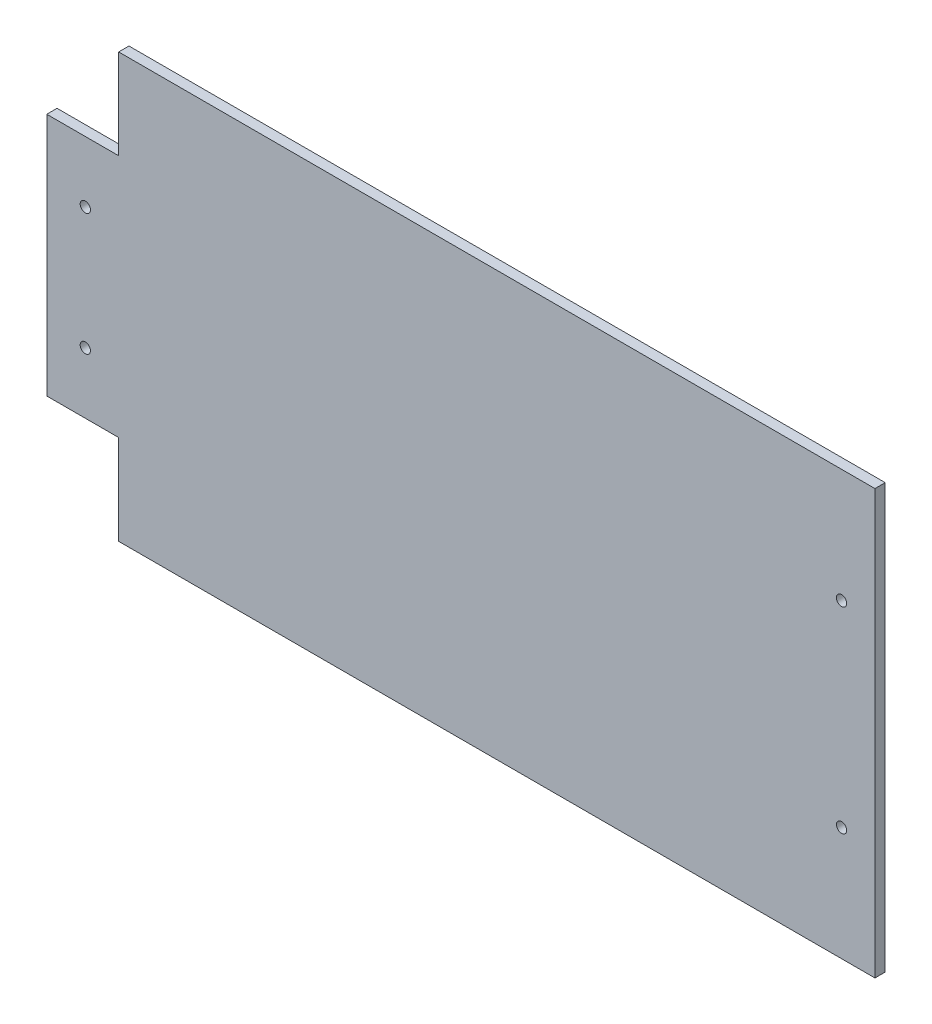
from build123d import *

# Parameters (mm, degrees)
SKETCH1_R           = 2
BOSS_EXTRUDE1_DEPTH = 4


with BuildPart() as part:
    # Sketch1 → Boss-Extrude1 (new body)
    with BuildSketch(Plane.XY):
        Polygon((-196.100746737, 58.609525438), (-168.100746718, 58.609525438), (-168.100746718, 93.60952561), (126.299253277, 93.60952561), (126.299253277, -71.390474628), (-168.100746738, -71.390474628), (-168.100746738, -36.390474581), (-196.100746737, -36.390474581), align=None)
        with Locations((-181.100722249, 34.859525457)):
            Circle(SKETCH1_R, mode=Mode.SUBTRACT)
        with Locations((-181.100722249, -12.640474497)):
            Circle(SKETCH1_R, mode=Mode.SUBTRACT)
        with Locations((113.299277706, 49.359525485)):
            Circle(SKETCH1_R, mode=Mode.SUBTRACT)
        with Locations((113.299277701, -27.140474515)):
            Circle(SKETCH1_R, mode=Mode.SUBTRACT)
    extrude(amount=BOSS_EXTRUDE1_DEPTH)


solid = part.part
